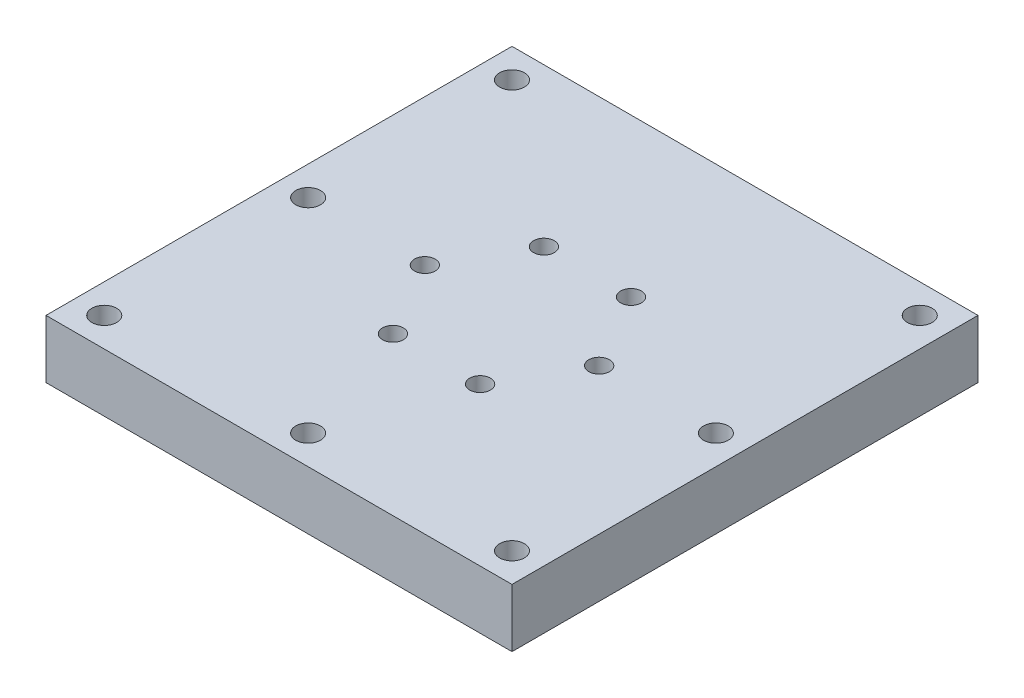
from build123d import *

# Parameters (mm, degrees)
SKETCH1_W             = 50.8
SKETCH1_H             = 50.8
BOSS_EXTRUDE1_DEPTH   = 6.35
CIRPATTERN1_COUNT     = 6
F_6_32_TAPPED_HOLE1_D = 2.7051
SKETCH7_R             = 2.38125
CUT_EXTRUDE1_DEPTH    = 22.225
F_6_32_TAPPED_HOLE2_D = 2.7051


with BuildPart() as part:
    # Sketch1 → Boss-Extrude1 (new body)
    with BuildSketch(Plane(origin=(0, 0, 0), x_dir=(1, 0, 0), z_dir=(0, 1, 0))):
        Rectangle(SKETCH1_W, SKETCH1_H)
    extrude(amount=BOSS_EXTRUDE1_DEPTH)

    # Sketch4 → 4-40 Tapped Hole1 (revolve, cut)
    with BuildSketch(Plane(origin=(4.75, 6.35, -8.227241336), x_dir=(0, 0, 1), z_dir=(1, 0, 0))):
        Polygon((0, 0), (0, 8.273752758), (1.1303, 7.5946), (1.1303, 0), align=None)
    f_4_40_tapped_hole1 = revolve(axis=Axis((4.75, 12.7, -8.227241336), (0, -1, 0)), mode=Mode.SUBTRACT)

    # CirPattern1: 4-40 Tapped Hole1 ×6 about axis
    cirpattern1_axis = Axis((0, 0, 0), (0, 1, 0))
    for i in range(1, CIRPATTERN1_COUNT):
        add(f_4_40_tapped_hole1.rotate(cirpattern1_axis, i * 360 / CIRPATTERN1_COUNT), mode=Mode.SUBTRACT)

    # 6-32 Tapped Hole1 (through all)
    with Locations(Plane(origin=(0, 6.35, 0), x_dir=(1, 0, 0), z_dir=(0, 1, 0))):
        with Locations((22.225, -22.225), (-22.225, 22.225), (-22.225, -22.225), (22.225, 22.225)):
            Hole(F_6_32_TAPPED_HOLE1_D / 2)

    # Sketch7 → Cut-Extrude1 (cut)
    with BuildSketch(Plane(origin=(0, 0, -25.4), x_dir=(-1, 0, 0), z_dir=(0, 0, -1))):
        with Locations((0, 3.175)):
            Circle(SKETCH7_R)
    extrude(amount=-CUT_EXTRUDE1_DEPTH, mode=Mode.SUBTRACT)

    # 6-32 Tapped Hole2 (through all)
    with Locations(Plane(origin=(0, 6.35, 0), x_dir=(1, 0, 0), z_dir=(0, 1, 0))):
        with Locations((22.225, 0), (-22.225, 0), (0, -22.225)):
            Hole(F_6_32_TAPPED_HOLE2_D / 2)


solid = part.part
